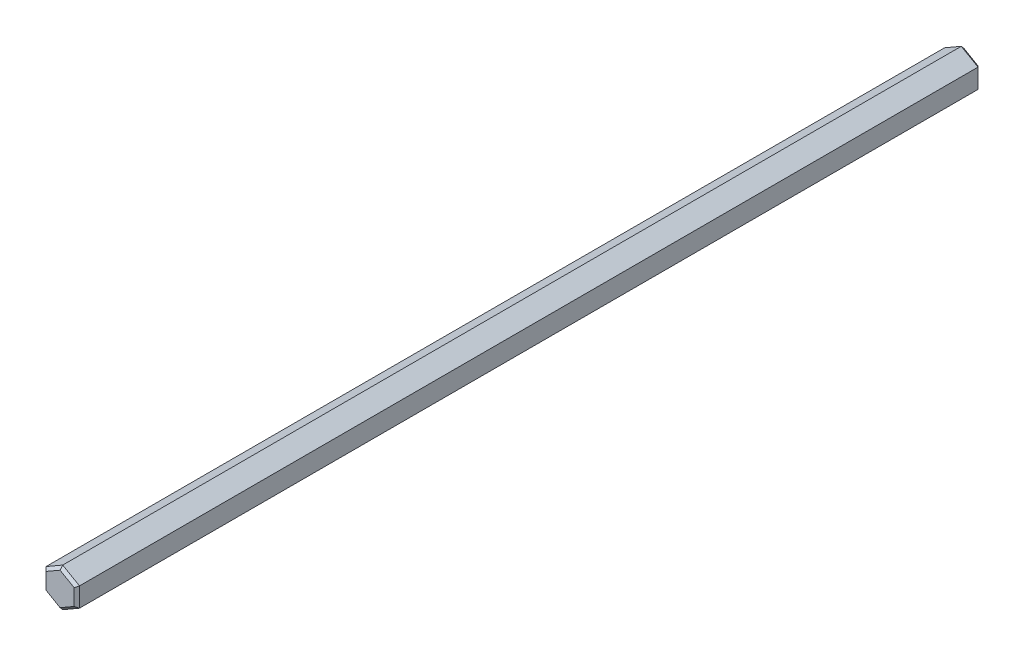
from build123d import *

# Parameters (mm, degrees)
BOSS_EXTRUDE1_DEPTH = 135
CHAMFER1_SIZE       = 0.4


with BuildPart() as part:
    # Sketch1 → Boss-Extrude1 (new body)
    with BuildSketch(Plane.XY.offset(67.5)):
        Polygon((0, -2.886751346), (2.5, -1.443375673), (2.5, 1.443375673), (0, 2.886751346), (-2.5, 1.443375673), (-2.5, -1.443375673), align=None)
    extrude(amount=-BOSS_EXTRUDE1_DEPTH)

    # Chamfer1
    chamfer1_edges = [part.edges().sort_by_distance(p)[0] for p in [
        (2.5, 0, -67.5),
        (1.25, 2.165063509, -67.5),
        (-1.25, 2.165063509, -67.5),
        (-2.5, 0, -67.5),
        (-1.25, -2.165063509, -67.5),
        (-2.5, 0, 67.5),
        (-1.25, 2.165063509, 67.5),
        (1.25, 2.165063509, 67.5),
        (1.25, -2.165063509, -67.5),
        (2.5, 0, 67.5),
        (1.25, -2.165063509, 67.5),
        (-1.25, -2.165063509, 67.5),
    ]]
    chamfer(chamfer1_edges, length=CHAMFER1_SIZE)


solid = part.part
